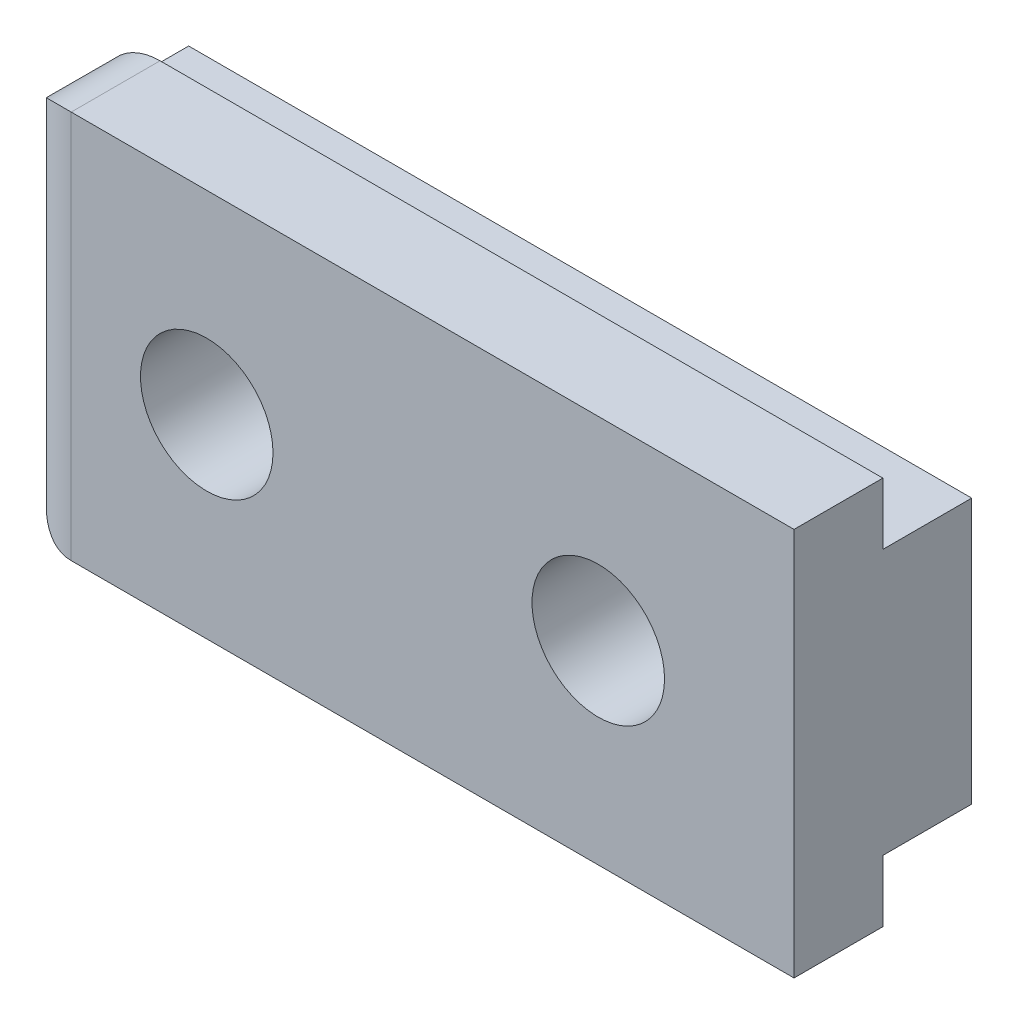
from build123d import *

# Parameters (mm, degrees)
SKETCH1_W                                    = 26
SKETCH1_H                                    = 12.9
BOSS_EXTRUDE1_DEPTH                          = 5.9
SKETCH2_W                                    = 2.95
SKETCH2_H                                    = 2.05
CUT_EXTRUDE1_DEPTH                           = 27
CSK_SLOT_FOR_M2_COUNTERSUNK_FLAT_HEA_2_COUNT = 2
CSK_SLOT_FOR_M2_COUNTERSUNK_FLAT_HEA_2_PITCH = 13
FILLET1_R                                    = 2


with BuildPart() as part:
    # Sketch1 → Boss-Extrude1 (new body)
    with BuildSketch(Plane.XY):
        Rectangle(SKETCH1_W, SKETCH1_H)
    extrude(amount=BOSS_EXTRUDE1_DEPTH)

    # Sketch2 → Cut-Extrude1 (cut, through all)
    with BuildSketch(Plane(origin=(13, 0, 0), x_dir=(0, 0, -1), z_dir=(1, 0, 0))):
        with Locations((-1.475, 5.425)):
            Rectangle(SKETCH2_W, SKETCH2_H)
        with Locations((-1.475, -5.425)):
            Rectangle(SKETCH2_W, SKETCH2_H)
    extrude(amount=-CUT_EXTRUDE1_DEPTH, mode=Mode.SUBTRACT)

    # Sketch3 → CSK SLOT for M2 Countersunk Flat Head Screw1 (revolve, cut)
    with BuildSketch(Plane(origin=(-6.5, 0, 5.9), x_dir=(0, -1, 0), z_dir=(1, 0, 0))):
        Polygon((0, 0), (0, 6.621032743), (1.2, 5.9), (1.2, 5.5), (2.2, 4.5), (2.2, 0), align=None)
    csk_slot_for_m2_countersunk_flat_head_sc = revolve(axis=Axis((-6.5, 0, 12.25), (0, 0, -1)), mode=Mode.SUBTRACT)

    # CSK SLOT for M2 Countersunk Flat Hea 2: CSK SLOT for M2 Countersunk Flat Head Screw1 ×2
    with Locations(*[(i * CSK_SLOT_FOR_M2_COUNTERSUNK_FLAT_HEA_2_PITCH, 0, 0) for i in range(1, CSK_SLOT_FOR_M2_COUNTERSUNK_FLAT_HEA_2_COUNT)]):
        add(csk_slot_for_m2_countersunk_flat_head_sc, mode=Mode.SUBTRACT)

    # Fillet1
    fillet1_edges = [part.edges().sort_by_distance(p)[0] for p in [
        (-13, 0, 5.9),
        (-13, 6.45, 4.425),
        (-13, -6.45, 4.425),
    ]]
    fillet(fillet1_edges, radius=FILLET1_R)


solid = part.part
